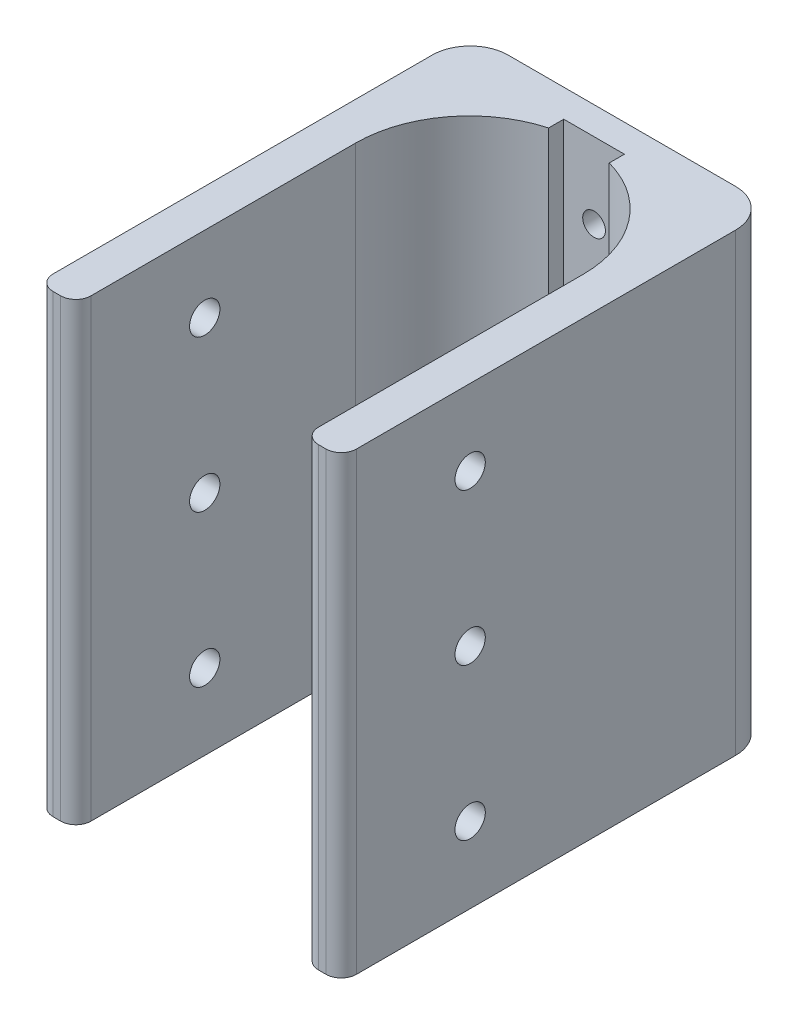
from build123d import *

# Parameters (mm, degrees)
EXTRUDE_1_DEPTH     = 60
SKETCH_2_R          = 1.5
CUT_EXTRUDE_1_DEPTH = 10
SKETCH_3_R          = 2
CUT_EXTRUDE_2_DEPTH = 41


with BuildPart() as part:
    # 草图1 → 凸台-拉伸1 (new body)
    with BuildSketch(Plane(origin=(0, 0, 0), x_dir=(1, 0, 0), z_dir=(0, 1, 0))):
        with BuildLine():
            Line((-33.288662304, -40.97966402), (-33.288662304, -6.09314479))
            ThreePointArc((-33.288662304, -6.09314479), (-30.22599869, 2.989806272), (-22.288662304, 8.363687504))
            Line((-22.288662304, 8.363687504), (-22.288662304, 10.363687504))
            Line((-22.288662304, 10.363687504), (-14.288662304, 10.363687504))
            Line((-14.288662304, 10.363687504), (-14.288662304, 8.363687504))
            ThreePointArc((-14.288662304, 8.363687504), (-6.351325918, 2.989806272), (-3.288662304, -6.09314479))
            Line((-3.288662304, -6.09314479), (-3.288662304, -40.97966402))
            ThreePointArc((-3.288662304, -40.97966402), (-2.702875867, -42.393877582), (-1.288662304, -42.97966402))
            Line((-1.288662304, -42.97966402), (-0.288662304, -42.97966402))
            ThreePointArc((-0.288662304, -42.97966402), (1.125551258, -42.393877582), (1.711337696, -40.97966402))
            Line((1.711337696, -40.97966402), (1.711337696, 9.02033598))
            ThreePointArc((1.711337696, 9.02033598), (0.246871602, 12.555869886), (-3.288662304, 14.02033598))
            Line((-3.288662304, 14.02033598), (-33.288662304, 14.02033598))
            ThreePointArc((-33.288662304, 14.02033598), (-36.82419621, 12.555869886), (-38.288662304, 9.02033598))
            Line((-38.288662304, 9.02033598), (-38.288662304, -40.97966402))
            ThreePointArc((-38.288662304, -40.97966402), (-37.702875867, -42.393877582), (-36.288662304, -42.97966402))
            Line((-36.288662304, -42.97966402), (-35.288662304, -42.97966402))
            ThreePointArc((-35.288662304, -42.97966402), (-33.874448742, -42.393877582), (-33.288662304, -40.97966402))
        make_face()
    extrude(amount=EXTRUDE_1_DEPTH)

    # 草图2 → 切除-拉伸1 (cut)
    with BuildSketch(Plane.XY.offset(-10.363687504)):
        with Locations((-18.288662304, 50)):
            Circle(SKETCH_2_R)
        with Locations((-18.288662304, 30)):
            Circle(SKETCH_2_R)
        with Locations((-18.288662304, 10)):
            Circle(SKETCH_2_R)
    extrude(amount=-CUT_EXTRUDE_1_DEPTH, mode=Mode.SUBTRACT)

    # 草图3 → 切除-拉伸2 (cut, through all)
    with BuildSketch(Plane.ZY.offset(38.288662304)):
        with Locations((25.97966402, 50)):
            Circle(SKETCH_3_R)
        with Locations((25.97966402, 30)):
            Circle(SKETCH_3_R)
        with Locations((25.97966402, 10)):
            Circle(SKETCH_3_R)
    extrude(amount=-CUT_EXTRUDE_2_DEPTH, mode=Mode.SUBTRACT)


solid = part.part
